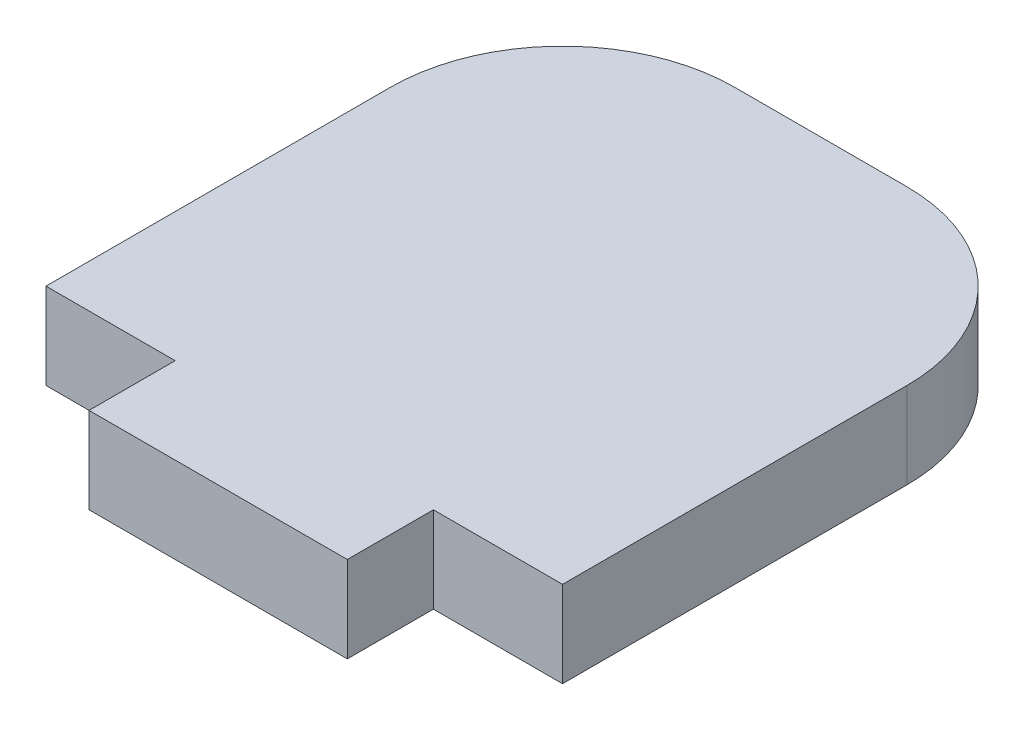
from build123d import *

# Parameters (mm, degrees)
BOSS_EXTRUDE1_DEPTH = 6.35


with BuildPart() as part:
    # Sketch1 → Boss-Extrude1 (new body)
    with BuildSketch(Plane(origin=(0, 0, 0), x_dir=(1, 0, 0), z_dir=(0, 1, 0))):
        with BuildLine():
            Line((9.525, -3.175), (-9.525, -3.175))
            Line((-9.525, -3.175), (-9.525, 3.175))
            Line((-9.525, 3.175), (-19.05, 3.175))
            Line((-19.05, 3.175), (-19.05, 28.575))
            ThreePointArc((-19.05, 28.575), (-15.330256121, 37.555256121), (-6.35, 41.275))
            Line((-6.35, 41.275), (6.35, 41.275))
            ThreePointArc((6.35, 41.275), (15.330256121, 37.555256121), (19.05, 28.575))
            Line((19.05, 28.575), (19.05, 3.175))
            Line((19.05, 3.175), (9.525, 3.175))
            Line((9.525, 3.175), (9.525, -3.175))
        make_face()
    extrude(amount=BOSS_EXTRUDE1_DEPTH)


solid = part.part
